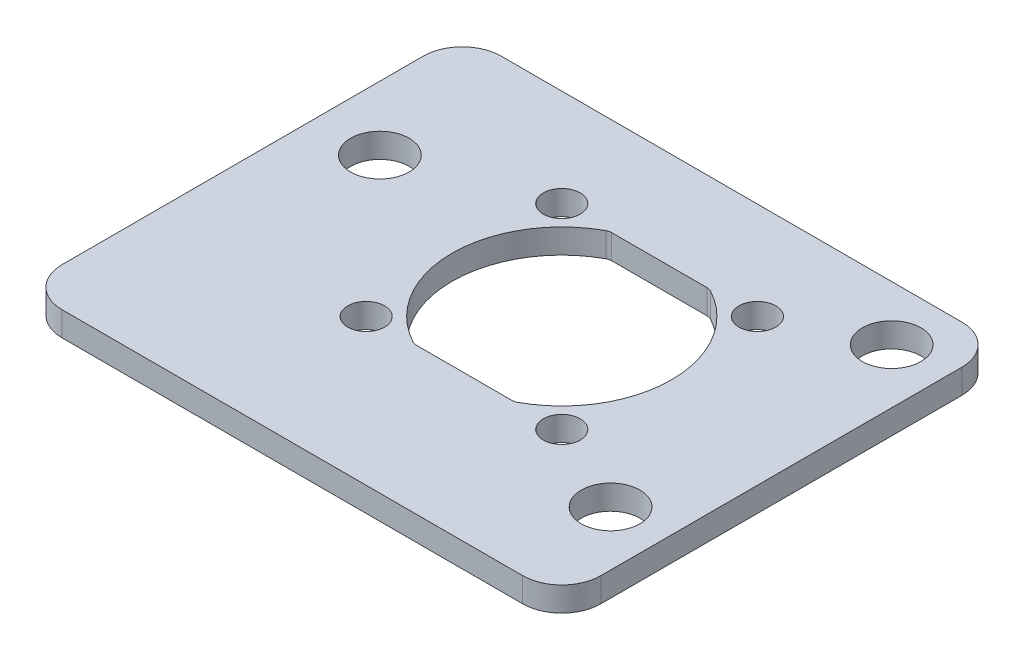
from build123d import *

# Parameters (mm, degrees)
SKETCH1_W           = 31.75
SKETCH1_H           = 25.4
SKETCH1_R           = 7.1374
SKETCH1_R_2         = 1.2
SKETCH1_R_3         = 1.905
BOSS_EXTRUDE1_DEPTH = 1.5875
SKETCH2_W           = 31.75
SKETCH2_H           = 3.175
BOSS_EXTRUDE2_DEPTH = 1.5875
SKETCH5_R           = 1.905
BOSS_EXTRUDE4_DEPTH = 1.5875
SKETCH6_R           = 1.905
CUT_EXTRUDE1_DEPTH  = 2.5875
BOSS_EXTRUDE3_DEPTH = 1.5875
FILLET2_R           = 0.635
FILLET3_R           = 2.54


with BuildPart() as part:
    # Sketch1 → Boss-Extrude1 (new body)
    with BuildSketch(Plane(origin=(0, 0, 0), x_dir=(1, 0, 0), z_dir=(0, 1, 0))):
        Rectangle(SKETCH1_W, SKETCH1_H)
        Circle(SKETCH1_R, mode=Mode.SUBTRACT)
        with Locations((-6.363961031, -6.363961031)):
            Circle(SKETCH1_R_2, mode=Mode.SUBTRACT)
        with Locations((-6.363961031, 6.363961031)):
            Circle(SKETCH1_R_2, mode=Mode.SUBTRACT)
        with Locations((6.363961031, 6.363961031)):
            Circle(SKETCH1_R_2, mode=Mode.SUBTRACT)
        with Locations((6.363961031, -6.363961031)):
            Circle(SKETCH1_R_2, mode=Mode.SUBTRACT)
        with Locations((-12.319, -9.144)):
            Circle(SKETCH1_R_3, mode=Mode.SUBTRACT)
        with Locations((-12.319, 9.144)):
            Circle(SKETCH1_R_3, mode=Mode.SUBTRACT)
        with Locations((12.319, 9.144)):
            Circle(SKETCH1_R_3, mode=Mode.SUBTRACT)
        with Locations((12.319, -9.144)):
            Circle(SKETCH1_R_3, mode=Mode.SUBTRACT)
    extrude(amount=BOSS_EXTRUDE1_DEPTH)

    # Sketch2 → Boss-Extrude2 (add, through all)
    with BuildSketch(Plane(origin=(0, 1.5875, 0), x_dir=(1, 0, 0), z_dir=(0, 1, 0))):
        with Locations((0, -14.2875)):
            Rectangle(SKETCH2_W, SKETCH2_H)
    extrude(amount=-BOSS_EXTRUDE2_DEPTH)

    # Sketch5 → Boss-Extrude4 (add, through all)
    with BuildSketch(Plane(origin=(0, 1.5875, 0), x_dir=(1, 0, 0), z_dir=(0, 1, 0))):
        with Locations((-12.319, 9.144)):
            Circle(SKETCH5_R)
        with Locations((-12.319, -9.144)):
            Circle(SKETCH5_R)
        with BuildLine():
            Line((-19.177, 12.7), (-15.875, 12.7))
            Line((-15.875, 12.7), (-15.875, 4.87211828))
            ThreePointArc((-15.875, 4.87211828), (-16.91465929, 3.175), (-15.875, 1.47788172))
            Line((-15.875, 1.47788172), (-15.875, -15.875))
            Line((-15.875, -15.875), (-19.177, -15.875))
            Line((-19.177, -15.875), (-19.177, 12.7))
        make_face()
    extrude(amount=-BOSS_EXTRUDE4_DEPTH)

    # Sketch6 → Cut-Extrude1 (cut, through all)
    with BuildSketch(Plane(origin=(0, 1.5875, 0), x_dir=(1, 0, 0), z_dir=(0, 1, 0))):
        with Locations((-15.00965929, 3.175)):
            Circle(SKETCH6_R)
    extrude(amount=-CUT_EXTRUDE1_DEPTH, mode=Mode.SUBTRACT)

    # Sketch3 → Boss-Extrude3 (add, through all)
    with BuildSketch(Plane(origin=(0, 1.5875, 0), x_dir=(1, 0, 0), z_dir=(0, 1, 0))):
        with BuildLine():
            Line((-3.258830889, 6.35), (3.258830889, 6.35))
            ThreePointArc((3.258830889, 6.35), (0, 7.1374), (-3.258830889, 6.35))
        make_face()
        with BuildLine():
            Line((3.258830889, -6.35), (-3.258830889, -6.35))
            ThreePointArc((-3.258830889, -6.35), (0, -7.1374), (3.258830889, -6.35))
        make_face()
    extrude(amount=-BOSS_EXTRUDE3_DEPTH)

    # Fillet2
    fillet2_edges = [part.edges().sort_by_distance(p)[0] for p in [
        (-3.258830889, 0.79375, -6.35),
        (3.258830889, 0.79375, -6.35),
        (3.258830889, 0.79375, 6.35),
        (-3.258830889, 0.79375, 6.35),
    ]]
    fillet(fillet2_edges, radius=FILLET2_R)

    # Fillet3
    fillet3_edges = [part.edges().sort_by_distance(p)[0] for p in [
        (15.875, 0.79375, 15.875),
        (-19.177, 0.79375, 15.875),
        (-19.177, 0.79375, -12.7),
        (15.875, 0.79375, -12.7),
    ]]
    fillet(fillet3_edges, radius=FILLET3_R)


solid = part.part
